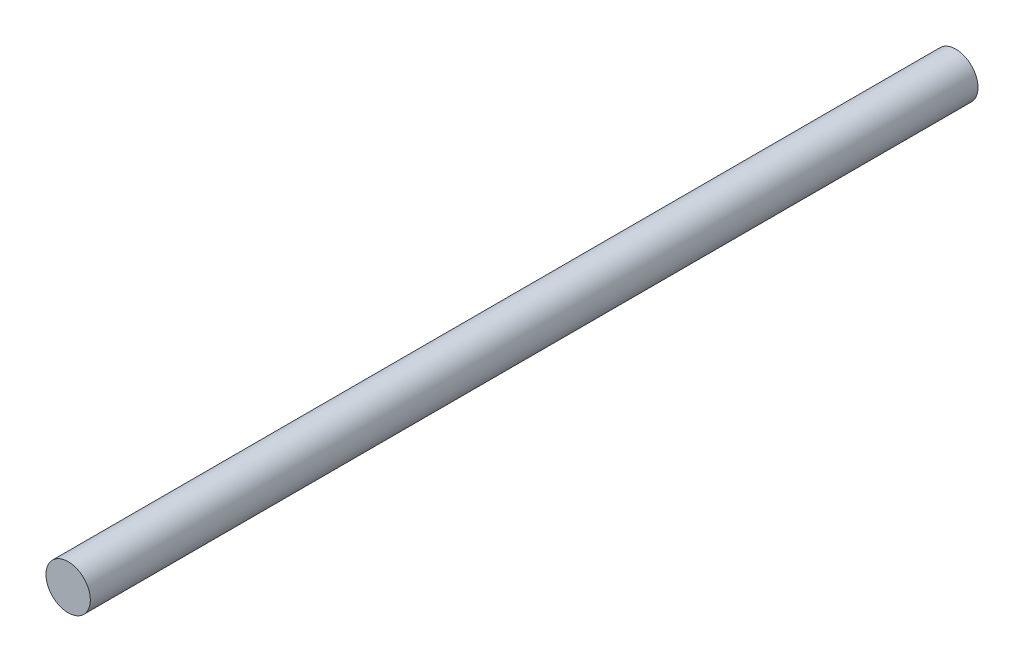
from build123d import *

# Parameters (mm, degrees)
ESQUISSE1_R        = 1.5
BOSS_EXTRU_1_DEPTH = 60


with BuildPart() as part:
    # Esquisse1 → Boss.-Extru.1 (new body)
    with BuildSketch(Plane.XY):
        Circle(ESQUISSE1_R)
    extrude(amount=BOSS_EXTRU_1_DEPTH)


solid = part.part
